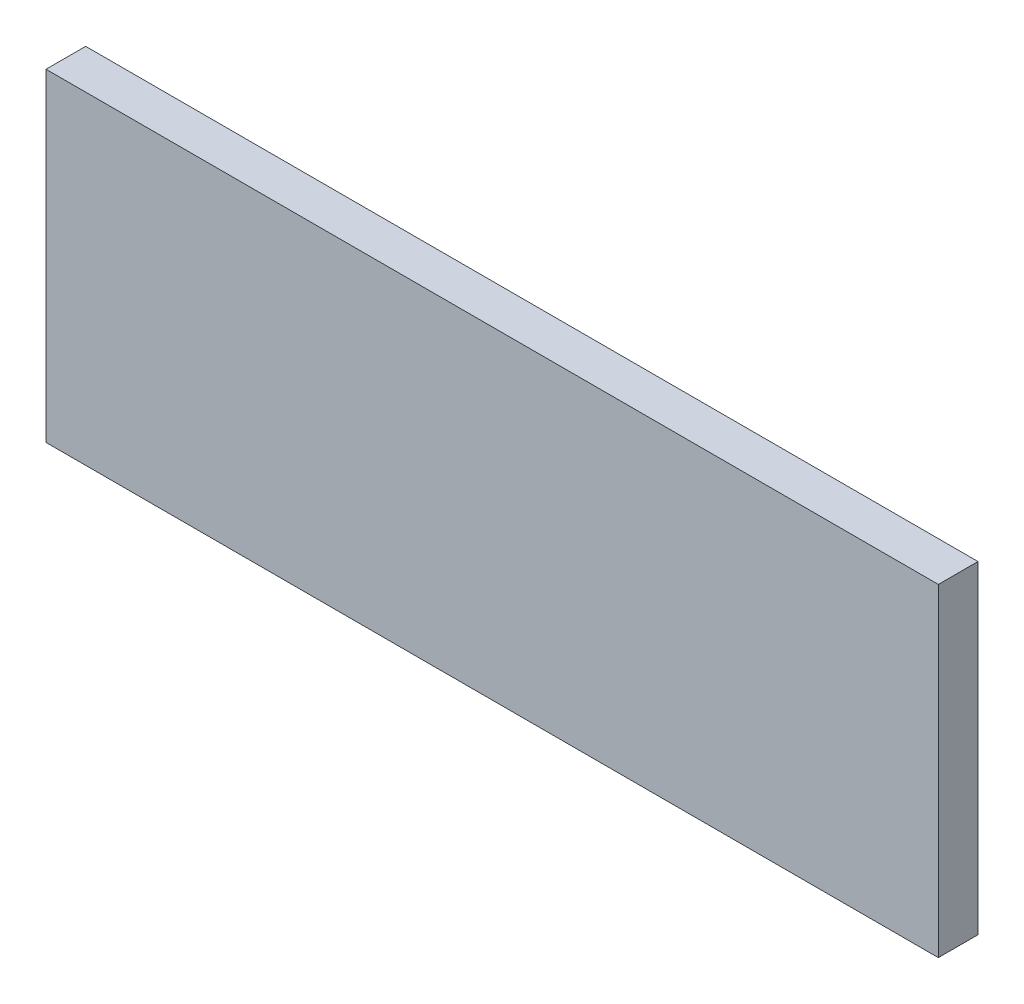
from build123d import *

# Parameters (mm, degrees)
SKETCH1_W           = 450
SKETCH1_H           = 163
BOSS_EXTRUDE1_DEPTH = 20


with BuildPart() as part:
    # Sketch1 → Boss-Extrude1 (new body)
    with BuildSketch(Plane.XY):
        Rectangle(SKETCH1_W, SKETCH1_H)
    extrude(amount=BOSS_EXTRUDE1_DEPTH)


solid = part.part
